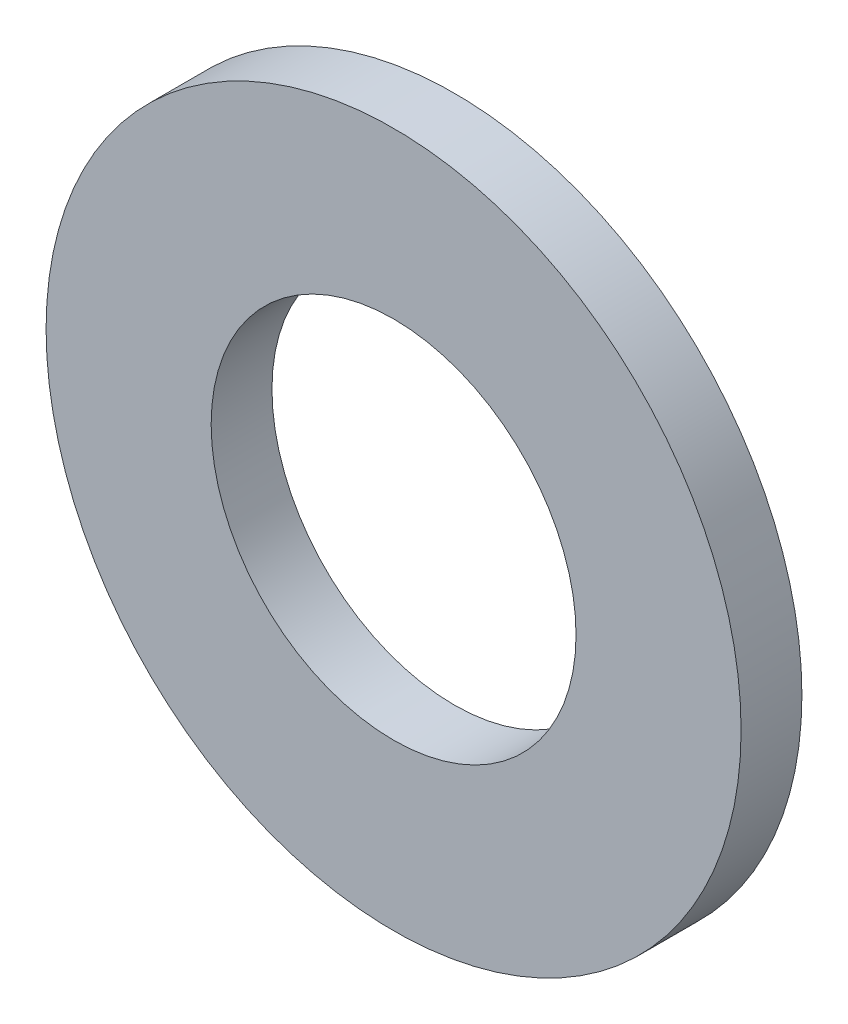
from build123d import *

# Parameters (mm, degrees)
SKETCH1_R      = 8
SKETCH1_R_2    = 4.2
EXTRUDE1_DEPTH = 1.4


with BuildPart() as part:
    # Sketch1 → Extrude1 (new body)
    with BuildSketch(Plane.XY):
        Circle(SKETCH1_R)
        Circle(SKETCH1_R_2, mode=Mode.SUBTRACT)
    extrude(amount=-EXTRUDE1_DEPTH)


solid = part.part
